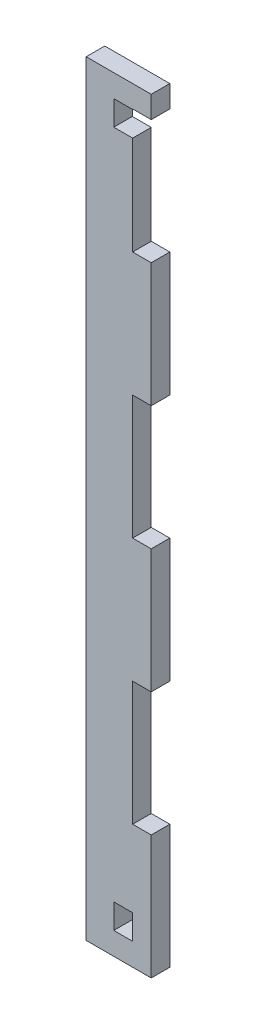
from build123d import *

# Parameters (mm, degrees)
ESQUISSE1_W        = 6.1
ESQUISSE1_H        = 8
BOSS_EXTRU_1_DEPTH = 6


with BuildPart() as part:
    # Esquisse1 → Boss.-Extru.1 (new body)
    with BuildSketch(Plane.XY):
        Polygon((-15, 181.409908735), (6, 181.409908735), (6, 174.308023863), (0, 174.308023863), (0, 174.159908735), (-6.1, 174.159908735), (-6.1, 166.159908735), (0, 166.159908735), (0, 134.309238722), (6, 134.309238722), (6, 94.307416433), (0, 94.307416433), (0, 54.308631292), (6, 54.308631292), (6, 14.306809003), (0, 14.306809003), (0, -25.691976137), (6, -25.691976137), (6, -65.693190997), (-15, -65.693190997), align=None)
        with Locations((-3.05, -54.443190997)):
            Rectangle(ESQUISSE1_W, ESQUISSE1_H, mode=Mode.SUBTRACT)
    extrude(amount=BOSS_EXTRU_1_DEPTH)


solid = part.part
